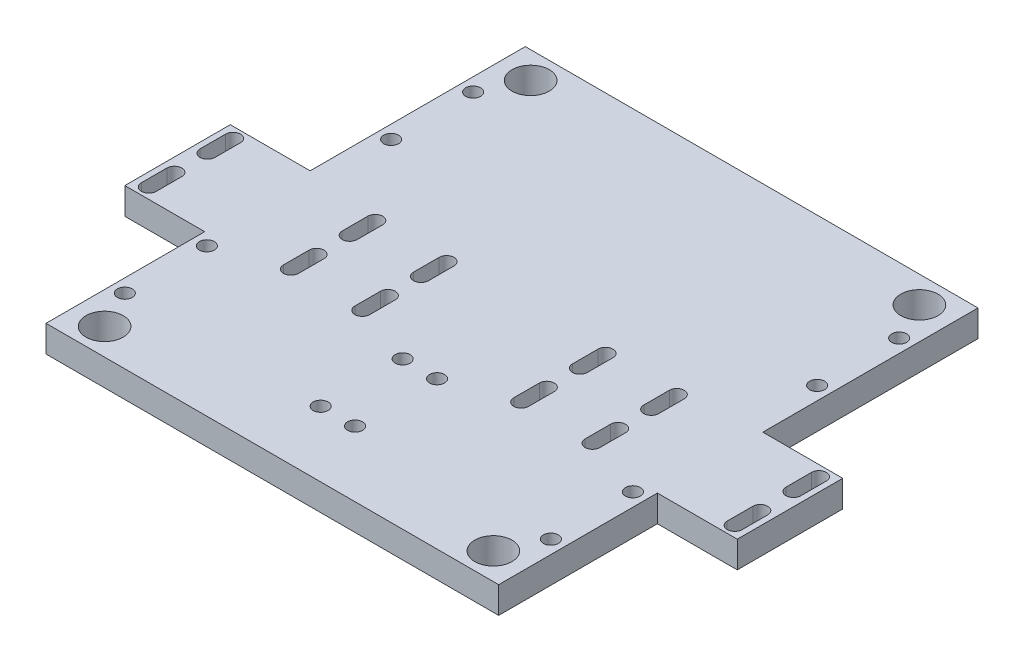
from build123d import *

# Parameters (mm, degrees)
BOSS_EXTRU_1_DEPTH      = 6.35
ESQUISSE4_R             = 1.778
ENL_V_MAT_EXTRU_2_DEPTH = 7.35
ESQUISSE7_R             = 4.445
ENL_V_MAT_EXTRU_3_DEPTH = 7.35


with BuildPart() as part:
    # Esquisse1 → Boss.-Extru.1 (new body)
    with BuildSketch(Plane(origin=(0, 0, 0), x_dir=(1, 0, 0), z_dir=(0, 1, 0))):
        Polygon((0, 0), (53.975, 0), (53.975, -51.308), (73.025, -51.308), (73.025, -76.454), (53.975, -76.454), (53.975, -114.3), (0, -114.3), align=None)
    boss_extru_1 = extrude(amount=BOSS_EXTRU_1_DEPTH)

    # Symétrie1: Boss.-Extru.1 across plane
    add(boss_extru_1.mirror(Plane(origin=(0, 0, 0), x_dir=(0, 0, 1), z_dir=(1, 0, 0))))

    # Esquisse4 → Enlèv. mat.-Extru.2 (cut, through all)
    with BuildSketch(Plane(origin=(0, 6.35, 0), x_dir=(1, 0, 0), z_dir=(0, 1, 0))):
        with Locations((-50.8, -15.621)):
            Circle(ESQUISSE4_R)
        with Locations((-50.8, -35.179)):
            Circle(ESQUISSE4_R)
        with Locations((50.8, -15.621)):
            Circle(ESQUISSE4_R)
        with Locations((50.8, -35.179)):
            Circle(ESQUISSE4_R)
        with Locations((-4.1, -98.679)):
            Circle(ESQUISSE4_R)
        with Locations((4.1, -98.679)):
            Circle(ESQUISSE4_R)
        with Locations((4.1, -79.121)):
            Circle(ESQUISSE4_R)
        with Locations((-4.1, -79.121)):
            Circle(ESQUISSE4_R)
        with Locations((-50.8, -98.679)):
            Circle(ESQUISSE4_R)
        with Locations((-50.8, -79.121)):
            Circle(ESQUISSE4_R)
        with Locations((50.8, -98.679)):
            Circle(ESQUISSE4_R)
        with Locations((50.8, -79.121)):
            Circle(ESQUISSE4_R)
        with BuildLine():
            Line((-34.17200205, -53.807095184), (-34.17200205, -59.903095184))
            ThreePointArc((-34.17200205, -59.903095184), (-35.95000205, -61.681095184), (-37.72800205, -59.903095184))
            Line((-37.72800205, -59.903095184), (-37.72800205, -53.807095184))
            ThreePointArc((-37.72800205, -53.807095184), (-35.95000205, -52.029095184), (-34.17200205, -53.807095184))
        make_face()
        with BuildLine():
            Line((-17.17199795, -53.807095184), (-17.17199795, -59.903095184))
            ThreePointArc((-17.17199795, -59.903095184), (-18.94999795, -61.681095184), (-20.72799795, -59.903095184))
            Line((-20.72799795, -59.903095184), (-20.72799795, -53.807095184))
            ThreePointArc((-20.72799795, -53.807095184), (-18.94999795, -52.029095184), (-17.17199795, -53.807095184))
        make_face()
        with BuildLine():
            Line((-37.72800205, -67.807092584), (-37.72800205, -73.903092584))
            ThreePointArc((-37.72800205, -73.903092584), (-35.95000205, -75.681092584), (-34.17200205, -73.903092584))
            Line((-34.17200205, -73.903092584), (-34.17200205, -67.807092584))
            ThreePointArc((-34.17200205, -67.807092584), (-35.95000205, -66.029092584), (-37.72800205, -67.807092584))
        make_face()
        with BuildLine():
            Line((-20.72799795, -67.807092584), (-20.72799795, -73.903092584))
            ThreePointArc((-20.72799795, -73.903092584), (-18.94999795, -75.681092584), (-17.17199795, -73.903092584))
            Line((-17.17199795, -73.903092584), (-17.17199795, -67.807092584))
            ThreePointArc((-17.17199795, -67.807092584), (-18.94999795, -66.029092584), (-20.72799795, -67.807092584))
        make_face()
        with BuildLine():
            Line((17.17199795, -67.807092584), (17.17199795, -73.903092584))
            ThreePointArc((17.17199795, -73.903092584), (18.94999795, -75.681092584), (20.72799795, -73.903092584))
            Line((20.72799795, -73.903092584), (20.72799795, -67.807092584))
            ThreePointArc((20.72799795, -67.807092584), (18.94999795, -66.029092584), (17.17199795, -67.807092584))
        make_face()
        with BuildLine():
            Line((20.72799795, -53.807095184), (20.72799795, -59.903095184))
            ThreePointArc((20.72799795, -59.903095184), (18.94999795, -61.681095184), (17.17199795, -59.903095184))
            Line((17.17199795, -59.903095184), (17.17199795, -53.807095184))
            ThreePointArc((17.17199795, -53.807095184), (18.94999795, -52.029095184), (20.72799795, -53.807095184))
        make_face()
        with BuildLine():
            Line((34.17200205, -67.807092584), (34.17200205, -73.903092584))
            ThreePointArc((34.17200205, -73.903092584), (35.95000205, -75.681092584), (37.72800205, -73.903092584))
            Line((37.72800205, -73.903092584), (37.72800205, -67.807092584))
            ThreePointArc((37.72800205, -67.807092584), (35.95000205, -66.029092584), (34.17200205, -67.807092584))
        make_face()
        with BuildLine():
            Line((37.72800205, -53.807095184), (37.72800205, -59.903095184))
            ThreePointArc((37.72800205, -59.903095184), (35.95000205, -61.681095184), (34.17200205, -59.903095184))
            Line((34.17200205, -59.903095184), (34.17200205, -53.807095184))
            ThreePointArc((34.17200205, -53.807095184), (35.95000205, -52.029095184), (37.72800205, -53.807095184))
        make_face()
        with BuildLine():
            Line((-68.08100205, -53.807095184), (-68.08100205, -59.903095184))
            ThreePointArc((-68.08100205, -59.903095184), (-69.85900205, -61.681095184), (-71.63700205, -59.903095184))
            Line((-71.63700205, -59.903095184), (-71.63700205, -53.807095184))
            ThreePointArc((-71.63700205, -53.807095184), (-69.85900205, -52.029095184), (-68.08100205, -53.807095184))
        make_face()
        with BuildLine():
            Line((-71.63700205, -67.807092584), (-71.63700205, -73.903092584))
            ThreePointArc((-71.63700205, -73.903092584), (-69.85900205, -75.681092584), (-68.08100205, -73.903092584))
            Line((-68.08100205, -73.903092584), (-68.08100205, -67.807092584))
            ThreePointArc((-68.08100205, -67.807092584), (-69.85900205, -66.029092584), (-71.63700205, -67.807092584))
        make_face()
        with BuildLine():
            Line((68.08100205, -67.807092584), (68.08100205, -73.903092584))
            ThreePointArc((68.08100205, -73.903092584), (69.85900205, -75.681092584), (71.63700205, -73.903092584))
            Line((71.63700205, -73.903092584), (71.63700205, -67.807092584))
            ThreePointArc((71.63700205, -67.807092584), (69.85900205, -66.029092584), (68.08100205, -67.807092584))
        make_face()
        with BuildLine():
            Line((71.63700205, -53.807095184), (71.63700205, -59.903095184))
            ThreePointArc((71.63700205, -59.903095184), (69.85900205, -61.681095184), (68.08100205, -59.903095184))
            Line((68.08100205, -59.903095184), (68.08100205, -53.807095184))
            ThreePointArc((68.08100205, -53.807095184), (69.85900205, -52.029095184), (71.63700205, -53.807095184))
        make_face()
    extrude(amount=-ENL_V_MAT_EXTRU_2_DEPTH, mode=Mode.SUBTRACT)

    # Esquisse7 → Enlèv. mat.-Extru.3 (cut, through all)
    with BuildSketch(Plane(origin=(0, 6.35, 0), x_dir=(1, 0, 0), z_dir=(0, 1, 0))):
        with Locations((-46.355, -6.35)):
            Circle(ESQUISSE7_R)
        with Locations((46.355, -6.35)):
            Circle(ESQUISSE7_R)
        with Locations((-46.355, -107.95)):
            Circle(ESQUISSE7_R)
        with Locations((46.355, -107.95)):
            Circle(ESQUISSE7_R)
    extrude(amount=-ENL_V_MAT_EXTRU_3_DEPTH, mode=Mode.SUBTRACT)


solid = part.part
